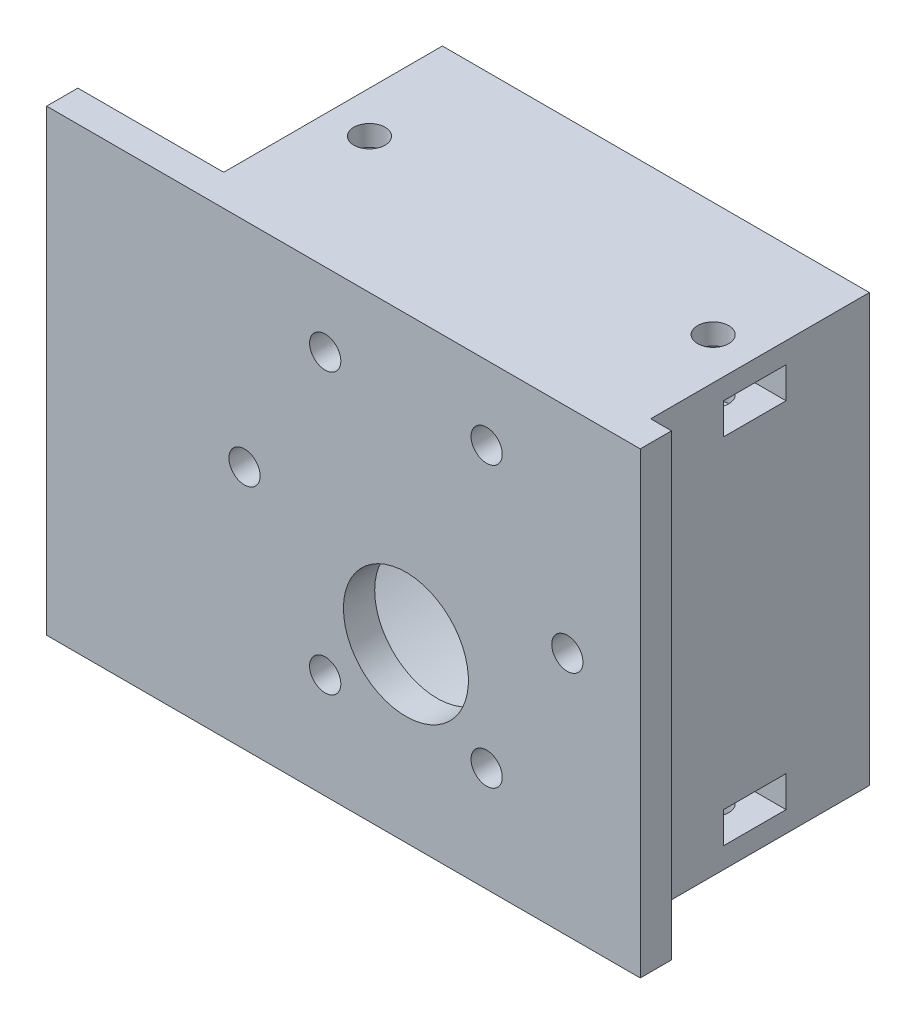
from build123d import *

# Parameters (mm, degrees)
SKETCH_1_W             = 69
SKETCH_1_H             = 44
EXTRUDE_624_DEPTH      = 3
SKETCH_2_R             = 1.5
SKETCH_2_R_2           = 6
CUT_EXTRUDE_837_DEPTH  = 3
SKETCH_4_R             = 20.5
SKETCH_4_R_2           = 18.5
EXTRUDE_1079_DEPTH     = 21
EXTRUDE_1525_DEPTH     = 21
SKETCH_20_W            = 1.345299462
SKETCH_20_H            = 6
CUT_EXTRUDE_2290_DEPTH = 3
SKETCH_21_W            = 1.345299462
SKETCH_21_H            = 6
CUT_EXTRUDE_2993_DEPTH = 3
SKETCH_11_W            = 41
SKETCH_11_H            = 2
EXTRUDE_3369_DEPTH     = 21
SKETCH_16_R            = 1.5
CUT_EXTRUDE_3664_DEPTH = 6.5
SKETCH_17_R            = 1.5
CUT_EXTRUDE_4007_DEPTH = 6.5
SKETCH_22_W            = 12
SKETCH_22_H            = 44
CUT_EXTRUDE_4241_DEPTH = 3
FILLET_1_R             = 1


with BuildPart() as part:
    # 草图1 → Extrude 624 (new body)
    with BuildSketch(Plane.XY):
        with Locations((0, -1.5)):
            Rectangle(SKETCH_1_W, SKETCH_1_H)
    extrude(amount=EXTRUDE_624_DEPTH)

    # 草图2 → Cut-Extrude 837 (cut)
    with BuildSketch(Plane(origin=(0, 0, 0), x_dir=(-1, 0, 0), z_dir=(0, 0, -1))):
        with Locations((-15.5, 0)):
            Circle(SKETCH_2_R)
        with Locations((-7.75, 13.423393759)):
            Circle(SKETCH_2_R)
        with Locations((7.75, 13.423393759)):
            Circle(SKETCH_2_R)
        with Locations((15.5, 0)):
            Circle(SKETCH_2_R)
        with Locations((7.75, -13.423393759)):
            Circle(SKETCH_2_R)
        with Locations((-7.75, -13.423393759)):
            Circle(SKETCH_2_R)
        with Locations((0, -7)):
            Circle(SKETCH_2_R_2)
    extrude(amount=-CUT_EXTRUDE_837_DEPTH, mode=Mode.SUBTRACT)

    # 草图4 → Extrude 1079 (add)
    with BuildSketch(Plane(origin=(0, 0, 0), x_dir=(-1, 0, 0), z_dir=(0, 0, -1))):
        Circle(SKETCH_4_R)
        Circle(SKETCH_4_R_2, mode=Mode.SUBTRACT)
    extrude(amount=EXTRUDE_1079_DEPTH)

    # 草图13 → Extrude 1525 (add)
    with BuildSketch(Plane(origin=(0, 0, 0), x_dir=(-1, 0, 0), z_dir=(0, 0, -1))):
        with BuildLine():
            Line((-20.5, 18.5), (-20.5, -3.7e-08))
            ThreePointArc((-20.5, -3.7e-08), (-17.339277644, 10.936153381), (-8.831760866, 18.5))
            Line((-8.831760866, 18.5), (-20.5, 18.5))
        make_face()
        with BuildLine():
            Line((-20.5, -18.5), (-8.831760866, -18.5))
            ThreePointArc((-8.831760866, -18.5), (-17.339277624, -10.936153413), (-20.5, -3.7e-08))
            Line((-20.5, -3.7e-08), (-20.5, -18.5))
        make_face()
        with BuildLine():
            Line((8.831760866, -18.5), (20.5, -18.5))
            Line((20.5, -18.5), (20.5, 0))
            ThreePointArc((20.5, 0), (17.339277634, -10.936153397), (8.831760866, -18.5))
        make_face()
        with BuildLine():
            ThreePointArc((8.831760866, 18.5), (17.339277634, 10.936153397), (20.5, 0))
            Line((20.5, 0), (20.5, 18.5))
            Line((20.5, 18.5), (8.831760866, 18.5))
        make_face()
    extrude(amount=EXTRUDE_1525_DEPTH)

    # 草图20 → Cut-Extrude 2290 (cut)
    with BuildSketch(Plane.XZ.offset(18.5)):
        Polygon((19.154700538, -11.401923789), (19.154700538, -7), (18.232050808, -7), (14.767949192, -7), (13.035898385, -10), (14.767949192, -13), (19.154700538, -13), align=None)
        Polygon((20.5, -7), (19.154700538, -7), (19.154700538, -11.401923789), (20.5, -9.07179677), align=None)
        Polygon((20.5, -9.07179677), (19.154700538, -11.401923789), (19.154700538, -13), (20.5, -13), align=None)
        with Locations((-19.827350269, -10)):
            Rectangle(SKETCH_20_W, SKETCH_20_H)
        Polygon((-14.767949192, -7), (-19.154700538, -7), (-19.154700538, -13), (-14.767949192, -13), (-13.035898385, -10), align=None)
    extrude(amount=-CUT_EXTRUDE_2290_DEPTH, mode=Mode.SUBTRACT)

    # 草图21 → Cut-Extrude 2993 (cut)
    with BuildSketch(Plane(origin=(0, 18.5, 0), x_dir=(1, 0, 0), z_dir=(0, 1, 0))):
        Polygon((19.154700538, 8.598076211), (19.154700538, 13), (18.232050808, 13), (14.767949192, 13), (13.035898385, 10), (14.767949192, 7), (19.154700538, 7), align=None)
        Polygon((20.5, 13), (19.154700538, 13), (19.154700538, 8.598076211), (20.5, 10.92820323), align=None)
        Polygon((20.5, 10.92820323), (19.154700538, 8.598076211), (19.154700538, 7), (20.5, 7), align=None)
        with Locations((-19.827350269, 10)):
            Rectangle(SKETCH_21_W, SKETCH_21_H)
        Polygon((-14.767949192, 13), (-19.154700538, 13), (-19.154700538, 7), (-14.767949192, 7), (-13.035898385, 10), align=None)
    extrude(amount=-CUT_EXTRUDE_2993_DEPTH, mode=Mode.SUBTRACT)

    # 草图11 → Extrude 3369 (add)
    with BuildSketch(Plane(origin=(0, 0, 0), x_dir=(-1, 0, 0), z_dir=(0, 0, -1))):
        with Locations((0, 19.5)):
            Rectangle(SKETCH_11_W, SKETCH_11_H)
        with Locations((0, -19.5)):
            Rectangle(SKETCH_11_W, SKETCH_11_H)
    extrude(amount=EXTRUDE_3369_DEPTH)

    # 草图16 → Cut-Extrude 3664 (cut)
    with BuildSketch(Plane.XZ.offset(20.5)):
        with Locations((-16.5, -10)):
            Circle(SKETCH_16_R)
        with Locations((16.5, -10)):
            Circle(SKETCH_16_R)
    extrude(amount=-CUT_EXTRUDE_3664_DEPTH, mode=Mode.SUBTRACT)

    # 草图17 → Cut-Extrude 4007 (cut)
    with BuildSketch(Plane(origin=(0, 20.5, 0), x_dir=(1, 0, 0), z_dir=(0, 1, 0))):
        with Locations((-16.5, 10)):
            Circle(SKETCH_17_R)
        with Locations((16.5, 10)):
            Circle(SKETCH_17_R)
    extrude(amount=-CUT_EXTRUDE_4007_DEPTH, mode=Mode.SUBTRACT)

    # 草图22 → Cut-Extrude 4241 (cut)
    with BuildSketch(Plane(origin=(0, 0, 0), x_dir=(-1, 0, 0), z_dir=(0, 0, -1))):
        with Locations((-28.5, -1.5)):
            Rectangle(SKETCH_22_W, SKETCH_22_H)
    extrude(amount=-CUT_EXTRUDE_4241_DEPTH, mode=Mode.SUBTRACT)

    # 圆角1
    fillet_1_edges = [part.edges().sort_by_distance(p)[0] for p in [
        (18.5, 0, 0),
    ]]
    fillet(fillet_1_edges, radius=FILLET_1_R)


solid = part.part
